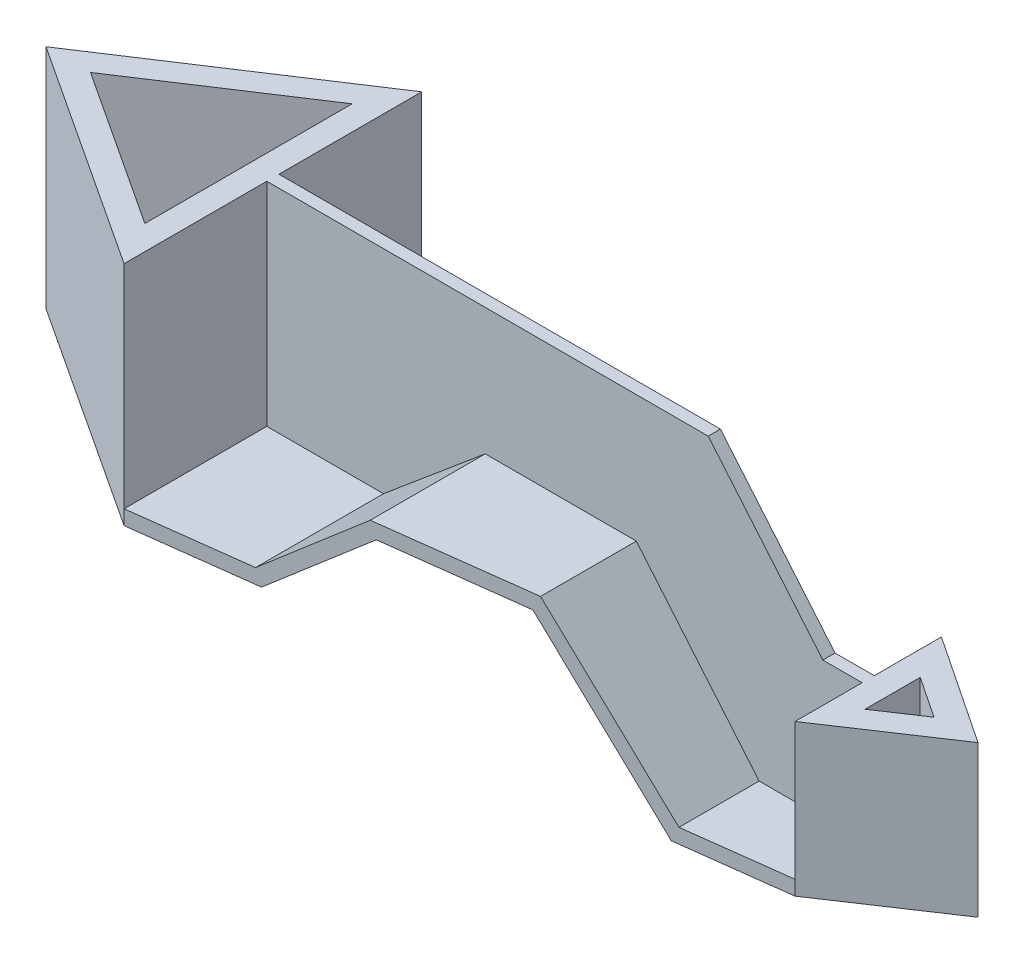
from build123d import *

# Parameters (mm, degrees)
BOSS_EXTRUDE1_DEPTH     = 93
BOSS_EXTRUDE2_DEPTH     = 61
BOSS_EXTRUDE3_START     = -25
BOSS_EXTRUDE3_DEPTH     = 62
BOSS_EXTRUDE4_DEPTH     = 2.5
CUT_EXTRUDE2_DEPTH      = 94
CUT_EXTRUDE2_DEPTH_BACK = 26


with BuildPart() as part:
    # Sketch2 → Boss-Extrude1 (new body)
    with BuildSketch(Plane(origin=(0, 0, 0), x_dir=(1, 0, 0), z_dir=(0, 1, 0))):
        Polygon((0, -61), (0, 61), (-93, 0), align=None)
        Polygon((-10, 42.481666483), (-74.767130868, 0), (-10, -42.481666483), align=None, mode=Mode.SUBTRACT)
    extrude(amount=BOSS_EXTRUDE1_DEPTH)

    # Sketch3 → Boss-Extrude2 (add, symmetric)
    with BuildSketch(Plane.XY):
        Polygon((0, 0), (50, 0), (91.711375741, 35), (148.654022129, 35), (199, -25), (244, -25), (244, -19), (201.797845949, -19), (151.451868078, 41), (89.527554335, 41), (47.816178594, 6), (0, 6), align=None)
    extrude(amount=BOSS_EXTRUDE2_DEPTH, both=True)

    # Sketch4 → Boss-Extrude3 (add)
    with BuildSketch(Plane(origin=(0, 0, 0), x_dir=(1, 0, 0), z_dir=(0, 1, 0)).offset(BOSS_EXTRUDE3_START)):
        Polygon((244, -30), (244, 30), (289, 0), align=None)
        Polygon((254, 11.314829082), (270.972243623, 0), (254, -11.314829082), align=None, mode=Mode.SUBTRACT)
    extrude(amount=BOSS_EXTRUDE3_DEPTH)

    # Sketch7 → Boss-Extrude4 (add, symmetric)
    with BuildSketch(Plane.XY):
        Polygon((0, 93), (180.92149546, 93), (227.911074806, 37), (244, 37), (244, -19), (201.797845949, -19), (151.451868078, 41), (89.527554335, 41), (47.816178594, 6), (0, 6), align=None)
    extrude(amount=BOSS_EXTRUDE4_DEPTH, both=True)

    # Sketch8 → Cut-Extrude2 (cut, two sides)
    with BuildSketch(Plane(origin=(0, 0, 0), x_dir=(1, 0, 0), z_dir=(0, 1, 0))) as cut_extrude2_sk:
        Polygon((0, 61), (244, 61), (244, 30), align=None)
        Polygon((0, -61), (244, -30), (244, -61), align=None)
    extrude(amount=CUT_EXTRUDE2_DEPTH, mode=Mode.SUBTRACT)
    extrude(cut_extrude2_sk.sketch, amount=-CUT_EXTRUDE2_DEPTH_BACK, mode=Mode.SUBTRACT)


solid = part.part
